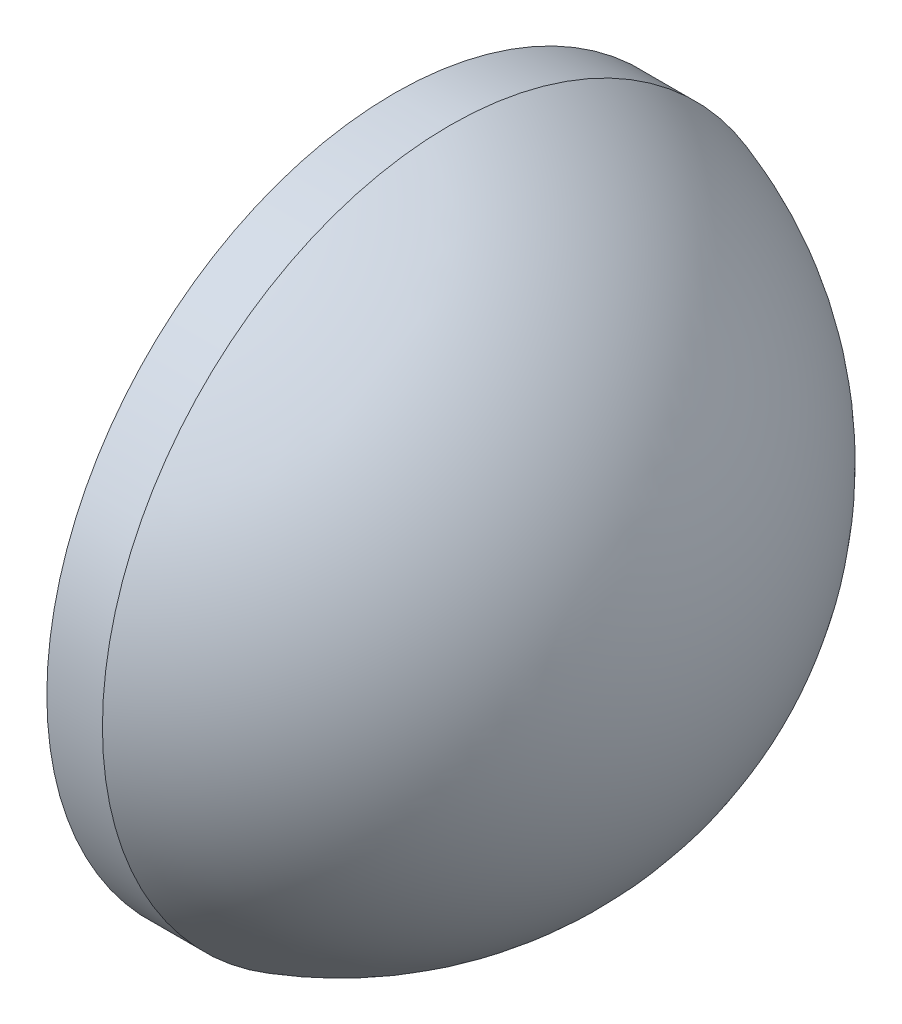
from build123d import *


with BuildPart() as part:
    # 草图1 → 旋转1 (revolve)
    with BuildSketch(Plane.XY, mode=Mode.PRIVATE) as revolve_1_sk:
        with BuildLine():
            Line((419.927886619, 66.577985104), (419.927886619, 79.077985104))
            Line((419.927886619, 79.077985104), (421.927886619, 79.077985104))
            ThreePointArc((421.927886619, 79.077985104), (428.552751889, 74.326462374), (431.087886619, 66.577985104))
            Line((431.087886619, 66.577985104), (419.927886619, 66.577985104))
        make_face()
    revolve(revolve_1_sk.sketch.rotate(Axis((417.4229376, 66.577985104, 0), (1, 0, 0)), 180), axis=Axis((417.4229376, 66.577985104, 0), (1, 0, 0)))  # turned: the seam where the file's is


solid = part.part
